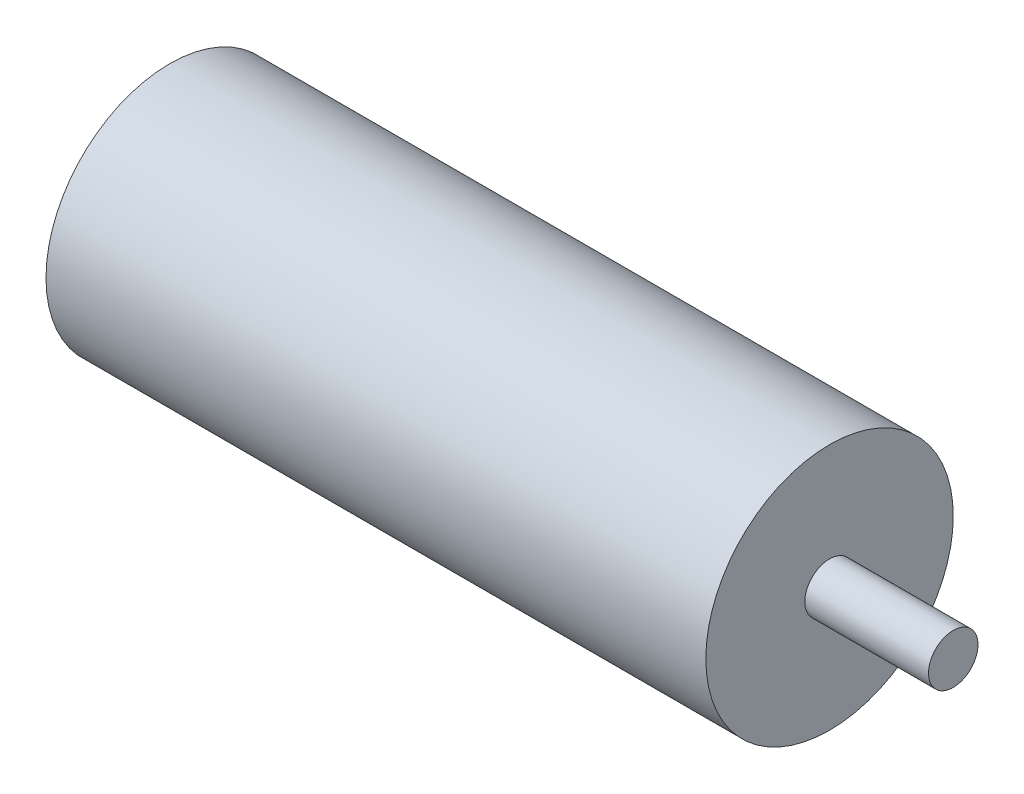
from build123d import *

# Parameters (mm, degrees)
SKETCH1_R           = 7.5
BOSS_EXTRUDE1_DEPTH = 45
SKETCH2_R           = 1.5
BOSS_EXTRUDE2_DEPTH = 15
SKETCH3_R           = 3.389534101
CUT_EXTRUDE1_DEPTH  = 7.5
SKETCH4_R           = 13.089152616
CUT_EXTRUDE2_DEPTH  = 5


with BuildPart() as part:
    # Sketch1 → Boss-Extrude1 (new body)
    with BuildSketch(Plane(origin=(0, 0, 0), x_dir=(0, 0, -1), z_dir=(1, 0, 0))):
        with Locations((-35.817726835, 20.099436521)):
            Circle(SKETCH1_R)
    extrude(amount=BOSS_EXTRUDE1_DEPTH)

    # Sketch2 → Boss-Extrude2 (add)
    with BuildSketch(Plane(origin=(45, 0, 0), x_dir=(0, 0, -1), z_dir=(1, 0, 0))):
        with Locations((-35.817726835, 20.099436521)):
            Circle(SKETCH2_R)
    extrude(amount=BOSS_EXTRUDE2_DEPTH)

    # Sketch3 → Cut-Extrude1 (cut)
    with BuildSketch(Plane(origin=(60, 0, 0), x_dir=(0, 0, -1), z_dir=(1, 0, 0))):
        with Locations((-35.761209842, 20.149750274)):
            Circle(SKETCH3_R)
    extrude(amount=-CUT_EXTRUDE1_DEPTH, mode=Mode.SUBTRACT)

    # Sketch4 → Cut-Extrude2 (cut)
    with BuildSketch(Plane.ZY):
        with Locations((34.849696462, 19.463840008)):
            Circle(SKETCH4_R)
    extrude(amount=-CUT_EXTRUDE2_DEPTH, mode=Mode.SUBTRACT)


solid = part.part
